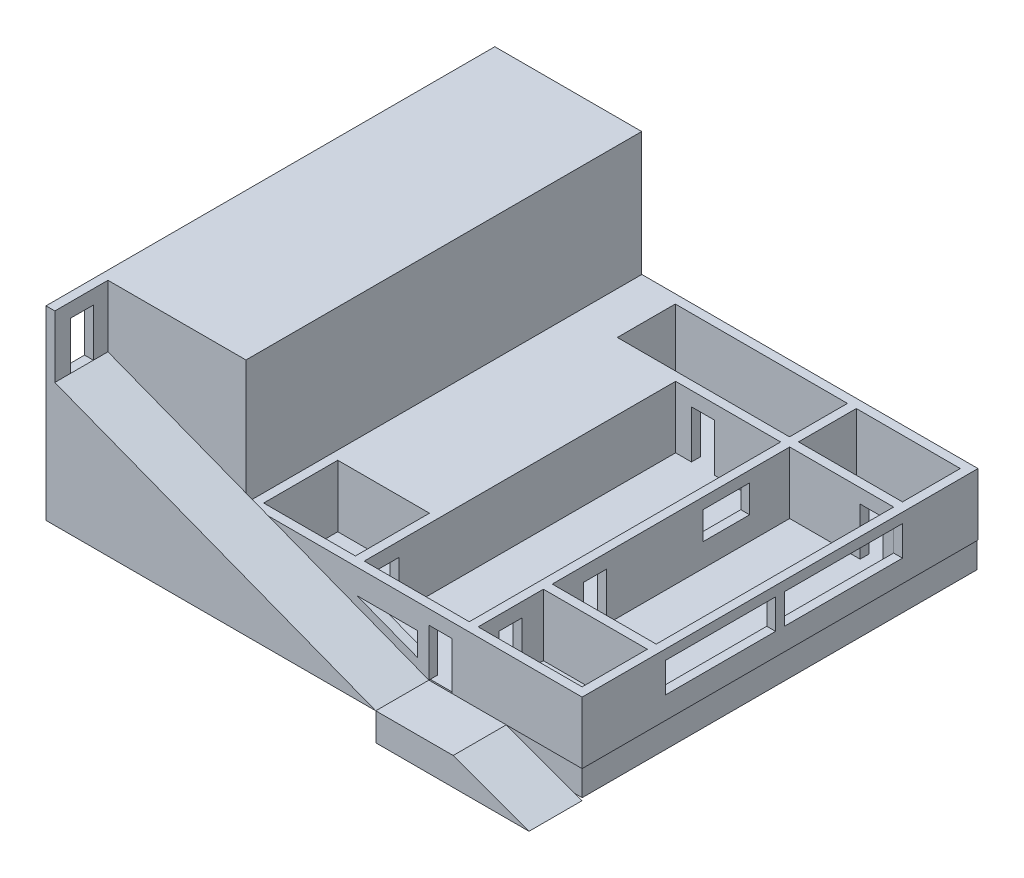
from build123d import *

# Parameters (mm, degrees)
ESBO_O2_W                 = 37.986253967
ESBO_O2_H                 = 44.734832406
ESBO_O2_W_2               = 11.750117276
ESBO_O2_H_2               = 7.37288194
ESBO_O2_W_3               = 11.871724424
ESBO_O2_H_3               = 35.18648103
ESBO_O2_H_4               = 26.831400584
ESBO_O2_H_5               = 6.530549882
ESBO_O2_W_4               = 19.456037254
ESBO_O2_H_6               = 6.548351376
ESBO_O2_W_5               = 10.364412267
ESBO_O2_H_7               = 8.37288194
RESSALTO_EXTRUS_O3_DEPTH  = 7
ESBO_O3_W                 = 2.6
ESBO_O3_H                 = 5.4
CORTE_EXTRUS_O1_DEPTH     = 7
ESBO_O4_W                 = 2.6
ESBO_O4_H                 = 5.4
CORTE_EXTRUS_O2_DEPTH     = 7
ESBO_O5_W                 = 2.6
ESBO_O5_H                 = 5.4
CORTE_EXTRUS_O3_DEPTH     = 7
ESBO_O6_W                 = 2.6
ESBO_O6_H                 = 5.4
CORTE_EXTRUS_O4_DEPTH     = 7
ESBO_O7_W                 = 12.456756284
ESBO_O7_H                 = 3.38294224
ESBO_O7_W_2               = 13.334930508
CORTE_EXTRUS_O5_DEPTH     = 7
ESBO_O8_W                 = 5.289229733
ESBO_O8_H                 = 3.129282188
CORTE_EXTRUS_O6_DEPTH     = 7
ESBO_O9_W                 = 16.596543628
ESBO_O9_H                 = 44.717687617
RESSALTO_EXTRUS_O4_DEPTH  = 21
ESBO_O10_W                = 1
ESBO_O10_H                = 7
RESSALTO_EXTRUS_O5_DEPTH  = 6
ESBO_O12_W                = 2.6
ESBO_O12_H                = 5.4
CORTE_EXTRUS_O7_DEPTH     = 6
RESSALTO_EXTRUS_O10_DEPTH = 6
ESBO_O14_W                = 54.431813347
ESBO_O14_H                = 44.622738474
RESSALTO_EXTRUS_O21_DEPTH = 3
CORTE_EXTRUS_O8_DEPTH     = 10


with BuildPart() as part:
    # Esboço2 → Ressalto-extrusão3 (new body)
    with BuildSketch(Plane(origin=(0, 0, 0), x_dir=(1, 0, 0), z_dir=(0, 1, 0))):
        with Locations((58.093256618, -15.481778526)):
            Rectangle(ESBO_O2_W, ESBO_O2_H)
        with Locations((70.211324964, -33.162753759)):
            Rectangle(ESBO_O2_W_2, ESBO_O2_H_2, mode=Mode.SUBTRACT)
        with Locations((57.400404114, -19.255954214)):
            Rectangle(ESBO_O2_W_3, ESBO_O2_H_3, mode=Mode.SUBTRACT)
        with Locations((70.211324964, -15.060612497)):
            Rectangle(ESBO_O2_W_2, ESBO_O2_H_4, mode=Mode.SUBTRACT)
        with Locations((70.211324964, 2.620362736)):
            Rectangle(ESBO_O2_W_2, ESBO_O2_H_5, mode=Mode.SUBTRACT)
        with Locations((53.608247699, 2.611461989)):
            Rectangle(ESBO_O2_W_4, ESBO_O2_H_6, mode=Mode.SUBTRACT)
        with Locations((45.282335769, -32.662753759)):
            Rectangle(ESBO_O2_W_5, ESBO_O2_H_7, mode=Mode.SUBTRACT)
    extrude(amount=RESSALTO_EXTRUS_O3_DEPTH)

    # Esboço3 → Corte-extrusão1 (cut)
    with BuildSketch(Plane.XY.offset(37.849194729)):
        with Locations((61.067460433, 2.683034247)):
            Rectangle(ESBO_O3_W, ESBO_O3_H)
    extrude(amount=-CORTE_EXTRUS_O1_DEPTH, mode=Mode.SUBTRACT)

    # Esboço4 → Corte-extrusão2 (cut)
    with BuildSketch(Plane(origin=(51.464541902, 0, 0), x_dir=(0, 0, -1), z_dir=(1, 0, 0))):
        with Locations((-34.211906201, 2.7)):
            Rectangle(ESBO_O4_W, ESBO_O4_H)
    extrude(amount=-CORTE_EXTRUS_O2_DEPTH, mode=Mode.SUBTRACT)

    # Esboço5 → Corte-extrusão3 (cut)
    with BuildSketch(Plane(origin=(64.336266326, 0, 0), x_dir=(0, 0, -1), z_dir=(1, 0, 0))):
        with Locations((-23.64357665, 2.7)):
            Rectangle(ESBO_O5_W, ESBO_O5_H)
        with Locations((-33.18821391, 2.7)):
            Rectangle(ESBO_O5_W, ESBO_O5_H)
    extrude(amount=-CORTE_EXTRUS_O3_DEPTH, mode=Mode.SUBTRACT)

    # Esboço6 → Corte-extrusão4 (cut)
    with BuildSketch(Plane.XY.offset(1.662713699)):
        with Locations((54.554214473, 2.7)):
            Rectangle(ESBO_O6_W, ESBO_O6_H)
        with Locations((73.594212294, 2.7)):
            Rectangle(ESBO_O6_W, ESBO_O6_H)
    extrude(amount=-CORTE_EXTRUS_O4_DEPTH, mode=Mode.SUBTRACT)

    # Esboço7 → Corte-extrusão5 (cut)
    with BuildSketch(Plane(origin=(77.086383602, 0, 0), x_dir=(0, 0, -1), z_dir=(1, 0, 0))):
        with Locations((-22.212770341, 4.19147112)):
            Rectangle(ESBO_O7_W, ESBO_O7_H)
        with Locations((-8.316926945, 4.19147112)):
            Rectangle(ESBO_O7_W_2, ESBO_O7_H)
    extrude(amount=-CORTE_EXTRUS_O5_DEPTH, mode=Mode.SUBTRACT)

    # Esboço8 → Corte-extrusão6 (cut)
    with BuildSketch(Plane(origin=(64.336266326, 0, 0), x_dir=(0, 0, -1), z_dir=(1, 0, 0))):
        with Locations((-8.813569548, 4.191268224)):
            Rectangle(ESBO_O8_W, ESBO_O8_H)
    extrude(amount=-CORTE_EXTRUS_O6_DEPTH, mode=Mode.SUBTRACT)

    # Esboço9 → Ressalto-extrusão4 (add)
    with BuildSketch(Plane(origin=(0, 0, 0), x_dir=(1, 0, 0), z_dir=(0, 1, 0))):
        with Locations((30.801857821, -15.490350921)):
            Rectangle(ESBO_O9_W, ESBO_O9_H)
    extrude(amount=RESSALTO_EXTRUS_O4_DEPTH)

    # Esboço10 → Ressalto-extrusão5 (add)
    with BuildSketch(Plane.XY.offset(37.849194729)):
        with Locations((23.003586007, 17.5)):
            Rectangle(ESBO_O10_W, ESBO_O10_H)
    extrude(amount=RESSALTO_EXTRUS_O5_DEPTH)

    # Esboço12 → Corte-extrusão7 (cut)
    with BuildSketch(Plane(origin=(23.503586007, 0, 0), x_dir=(0, 0, -1), z_dir=(1, 0, 0))):
        with Locations((-40.793821366, 16.7)):
            Rectangle(ESBO_O12_W, ESBO_O12_H)
    extrude(amount=-CORTE_EXTRUS_O7_DEPTH, mode=Mode.SUBTRACT)

    # Esboço11 → Ressalto-extrusão10 (add)
    with BuildSketch(Plane.XY.offset(37.849194729)):
        Polygon((39.100129635, 7.978811855), (23.503586007, 14), (22.503586007, 14), (22.503586007, 0), (59.767460433, 0), (41.63552322, 7), (39.100129635, 7), align=None)
        Polygon((62.367460433, 0), (59.767460433, 0), (59.767460433, -3.133265808), (77.086383602, -3.133265808), (68.515290094, 0), align=None)
        Polygon((41.63552322, 7), (39.100129635, 7.978811855), (39.100129635, 7), align=None)
    extrude(amount=RESSALTO_EXTRUS_O10_DEPTH)

    # Esboço14 → Ressalto-extrusão21 (add)
    with BuildSketch(Plane(origin=(0, 0, 0), x_dir=(1, 0, 0), z_dir=(0, 1, 0))):
        with Locations((49.719492681, -15.380529079)):
            Rectangle(ESBO_O14_W, ESBO_O14_H)
    extrude(amount=-RESSALTO_EXTRUS_O21_DEPTH)

    # Esboço15 → Corte-extrusão8 (cut)
    with BuildSketch(Plane.XY.offset(37.849194729)):
        Polygon((51.640321605, 4.209489794), (58.47658994, 1.570285952), (58.47658994, 4.209489794), align=None)
    extrude(amount=-CORTE_EXTRUS_O8_DEPTH, mode=Mode.SUBTRACT)


solid = part.part
